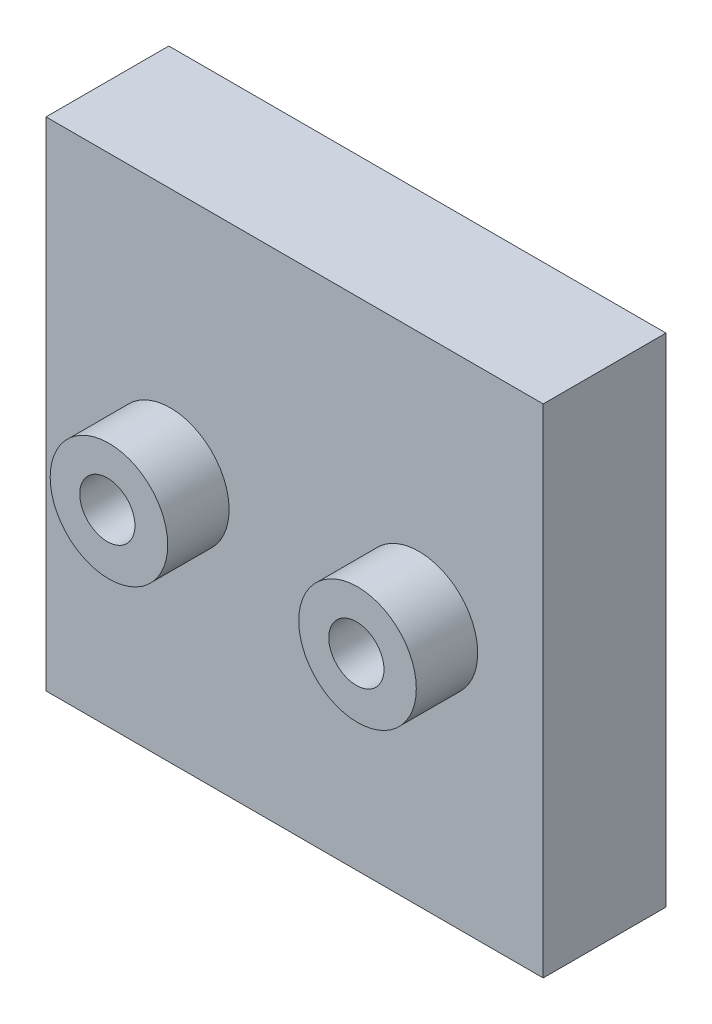
from build123d import *

# Parameters (mm, degrees)
SKETCH1_W           = 81
SKETCH1_H           = 20
BOSS_EXTRUDE2_DEPTH = 81
SKETCH2_R           = 9.5758
BOSS_EXTRUDE4_DEPTH = 10
SKETCH4_R           = 4.4958
CUT_EXTRUDE1_DEPTH  = 10


with BuildPart() as part:
    # Sketch1 → Boss-Extrude2 (new body)
    with BuildSketch(Plane(origin=(0, 0, 0), x_dir=(1, 0, 0), z_dir=(0, 1, 0))):
        Rectangle(SKETCH1_W, SKETCH1_H)
    extrude(amount=BOSS_EXTRUDE2_DEPTH)

    # Sketch2 → Boss-Extrude4 (add)
    with BuildSketch(Plane.XY.offset(10)):
        with Locations((-20.25, 40.5)):
            Circle(SKETCH2_R)
        with Locations((20.25, 40.5)):
            Circle(SKETCH2_R)
    extrude(amount=BOSS_EXTRUDE4_DEPTH)

    # Sketch4 → Cut-Extrude1 (cut)
    with BuildSketch(Plane.XY.offset(20)):
        with Locations((-20.510853934, 40.5563485)):
            Circle(SKETCH4_R)
        with Locations((20.060065936, 40.5563485)):
            Circle(SKETCH4_R)
    extrude(amount=-CUT_EXTRUDE1_DEPTH, mode=Mode.SUBTRACT)


solid = part.part
